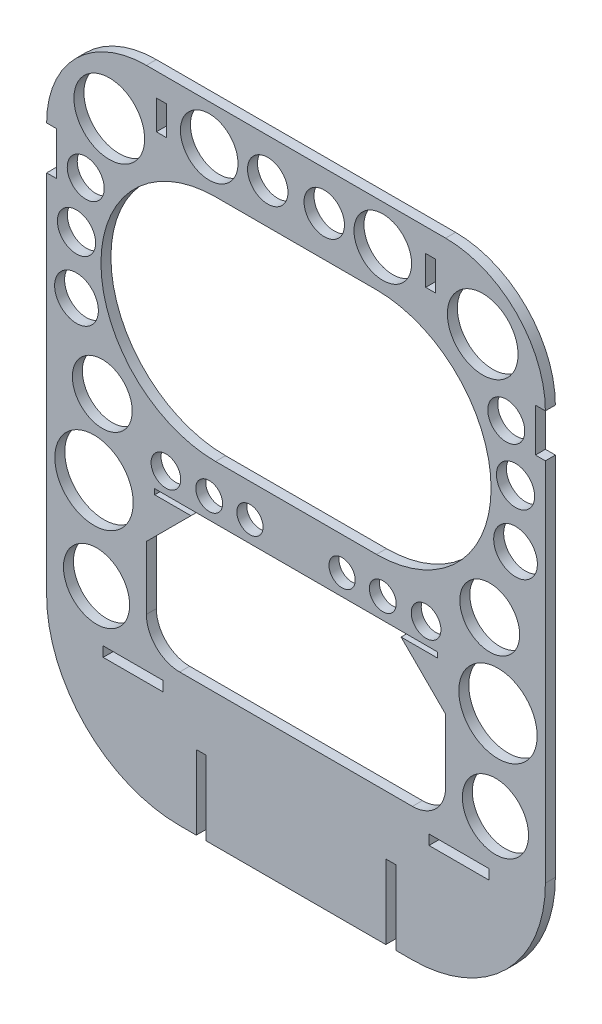
from build123d import *

# Parameters (mm, degrees)
BOSS_EXTRUDE1_DEPTH = 3
SKETCH2_W           = 90
SKETCH2_H           = 44
CUT_EXTRUDE1_DEPTH  = 10
FILLET1_R           = 10
CHAMFER1_SIZE       = 15
SKETCH3_W           = 85
SKETCH3_H           = 1.6
CUT_EXTRUDE2_DEPTH  = 10
SKETCH5_W           = 3
SKETCH5_H           = 13
SKETCH5_H_2         = 8.82
SKETCH5_W_2         = 18
SKETCH5_H_3         = 3
SKETCH5_H_4         = 22.31
CUT_EXTRUDE3_DEPTH  = 10
CUT_EXTRUDE4_DEPTH  = 10
SKETCH7_R           = 10.631131443
SKETCH7_R_2         = 8.661974079
SKETCH7_R_3         = 5.563912072
SKETCH7_R_4         = 5.743787148
SKETCH7_R_5         = 6.57513677
SKETCH7_R_6         = 8.998042507
SKETCH7_R_7         = 11.788086797
SKETCH7_R_8         = 9.954868747
SKETCH7_R_9         = 6.082926802
SKETCH7_R_10        = 4.464279257
SKETCH7_R_11        = 4.037680116
SKETCH7_R_12        = 3.945902669
CUT_EXTRUDE5_DEPTH  = 10


with BuildPart() as part:
    # Sketch1 → Boss-Extrude1 (new body)
    with BuildSketch(Plane.XY):
        with BuildLine():
            Line((-45, 96.5), (45, 96.5))
            ThreePointArc((45, 96.5), (66.213203436, 87.713203436), (75, 66.5))
            Line((75, 66.5), (75, -56.5))
            ThreePointArc((75, -56.5), (63.284271247, -84.784271247), (35, -96.5))
            Line((35, -96.5), (0.5, -96.5))
            Line((0.5, -96.5), (-0.5, -96.5))
            Line((-0.5, -96.5), (-35, -96.5))
            ThreePointArc((-35, -96.5), (-63.284271247, -84.784271247), (-75, -56.5))
            Line((-75, -56.5), (-75, 66.5))
            ThreePointArc((-75, 66.5), (-66.213203436, 87.713203436), (-45, 96.5))
        make_face()
    extrude(amount=BOSS_EXTRUDE1_DEPTH)

    # Sketch2 → Cut-Extrude1 (cut)
    with BuildSketch(Plane.XY.offset(3)):
        with Locations((0, -34.5)):
            Rectangle(SKETCH2_W, SKETCH2_H)
    extrude(amount=-CUT_EXTRUDE1_DEPTH, mode=Mode.SUBTRACT)

    # Fillet1
    fillet1_edges = [part.edges().sort_by_distance(p)[0] for p in [
        (45, -56.5, 1.5),
        (-45, -56.5, 1.5),
    ]]
    fillet(fillet1_edges, radius=FILLET1_R)

    # Chamfer1
    chamfer1_edges = [part.edges().sort_by_distance(p)[0] for p in [
        (45, -12.5, 1.5),
        (-45, -12.5, 1.5),
    ]]
    chamfer(chamfer1_edges, length=CHAMFER1_SIZE)

    # Sketch3 → Cut-Extrude2 (cut)
    with BuildSketch(Plane(origin=(0, 0, 0), x_dir=(-1, 0, 0), z_dir=(0, 0, -1))):
        with Locations((0, -13.3)):
            Rectangle(SKETCH3_W, SKETCH3_H)
    extrude(amount=-CUT_EXTRUDE2_DEPTH, mode=Mode.SUBTRACT)

    # Sketch5 → Cut-Extrude3 (cut)
    with BuildSketch(Plane(origin=(0, 0, 0), x_dir=(-1, 0, 0), z_dir=(0, 0, -1))):
        with Locations((-73.5, 60)):
            Rectangle(SKETCH5_W, SKETCH5_H)
        with Locations((-40.5, 85.09)):
            Rectangle(SKETCH5_W, SKETCH5_H_2)
        with Locations((73.5, 60)):
            Rectangle(SKETCH5_W, SKETCH5_H)
        with Locations((40.5, 85.09)):
            Rectangle(SKETCH5_W, SKETCH5_H_2)
        with Locations((-49, -62.69)):
            Rectangle(SKETCH5_W_2, SKETCH5_H_3)
        with Locations((49, -62.69)):
            Rectangle(SKETCH5_W_2, SKETCH5_H_3)
        with Locations((28.5, -85.345)):
            Rectangle(SKETCH5_W, SKETCH5_H_4)
        with Locations((-28.5, -85.345)):
            Rectangle(SKETCH5_W, SKETCH5_H_4)
    extrude(amount=-CUT_EXTRUDE3_DEPTH, mode=Mode.SUBTRACT)

    # Sketch6 → Cut-Extrude4 (cut)
    with BuildSketch(Plane(origin=(0, 0, 0), x_dir=(-1, 0, 0), z_dir=(0, 0, -1))):
        with BuildLine():
            Line((-24.212655847, 72.63796754), (24.212655847, 72.63796754))
            ThreePointArc((24.212655847, 72.63796754), (58.665446775, 38.185176612), (24.212655847, 3.732385684))
            Line((24.212655847, 3.732385684), (-24.212655847, 3.732385684))
            ThreePointArc((-24.212655847, 3.732385684), (-58.665446775, 38.185176612), (-24.212655847, 72.63796754))
        make_face()
    extrude(amount=-CUT_EXTRUDE4_DEPTH, mode=Mode.SUBTRACT)

    # Sketch7 → Cut-Extrude5 (cut)
    with BuildSketch(Plane(origin=(0, 0, 0), x_dir=(-1, 0, 0), z_dir=(0, 0, -1))):
        with Locations((-56.155531371, 77.040268603)):
            Circle(SKETCH7_R)
        with Locations((-26.105041506, 84.696444365)):
            Circle(SKETCH7_R_2)
        with Locations((-63.23749395, 58.091233593)):
            Circle(SKETCH7_R_3)
        with Locations((-66.021045237, 42.587477675)):
            Circle(SKETCH7_R_4)
        with Locations((-66.021045237, 25.361082211)):
            Circle(SKETCH7_R_5)
        with Locations((-58.260979705, 4.306598866)):
            Circle(SKETCH7_R_6)
        with Locations((-60.749236828, -19.427545996)):
            Circle(SKETCH7_R_7)
        with Locations((-59.983619252, -46.60696995)):
            Circle(SKETCH7_R_8)
        with Locations((-8.495837254, 84.696444365)):
            Circle(SKETCH7_R_9)
        with Locations((-39.120540301, -6.220642806)):
            Circle(SKETCH7_R_10)
        with Locations((-26.105041506, -6.220642806)):
            Circle(SKETCH7_R_11)
        with Locations((-13.855160287, -6.220642806)):
            Circle(SKETCH7_R_12)
        with Locations((13.855160287, -6.220642806)):
            Circle(SKETCH7_R_12)
        with Locations((26.105041506, -6.220642806)):
            Circle(SKETCH7_R_11)
        with Locations((39.120540301, -6.220642806)):
            Circle(SKETCH7_R_10)
        with Locations((8.495837254, 84.696444365)):
            Circle(SKETCH7_R_9)
        with Locations((59.983619252, -46.60696995)):
            Circle(SKETCH7_R_8)
        with Locations((60.749236828, -19.427545996)):
            Circle(SKETCH7_R_7)
        with Locations((58.260979705, 4.306598866)):
            Circle(SKETCH7_R_6)
        with Locations((66.021045237, 25.361082211)):
            Circle(SKETCH7_R_5)
        with Locations((66.021045237, 42.587477675)):
            Circle(SKETCH7_R_4)
        with Locations((63.23749395, 58.091233593)):
            Circle(SKETCH7_R_3)
        with Locations((26.105041506, 84.696444365)):
            Circle(SKETCH7_R_2)
        with Locations((56.155531371, 77.040268603)):
            Circle(SKETCH7_R)
    extrude(amount=-CUT_EXTRUDE5_DEPTH, mode=Mode.SUBTRACT)


solid = part.part
